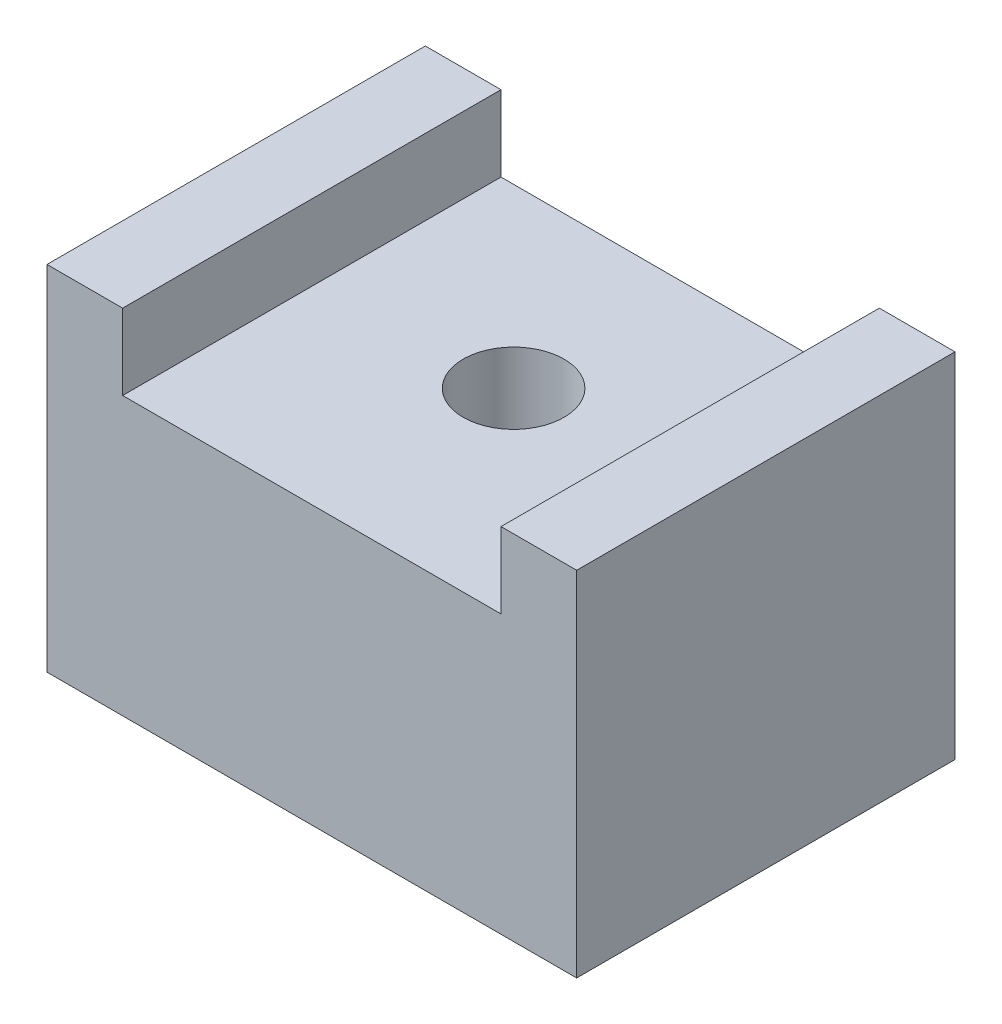
from build123d import *

# Parameters (mm, degrees)
BOSS_EXTRUDE1_DEPTH = 15
SKETCH2_R           = 2
CUT_EXTRUDE1_DEPTH  = 11


with BuildPart() as part:
    # Sketch1 → Boss-Extrude1 (new body)
    with BuildSketch(Plane.XY):
        Polygon((7.5, 0), (-7.5, 0), (-7.5, 3), (-10.5, 3), (-10.5, -11), (10.5, -11), (10.5, 3), (7.5, 3), align=None)
    extrude(amount=BOSS_EXTRUDE1_DEPTH)

    # Sketch2 → Cut-Extrude1 (cut)
    with BuildSketch(Plane(origin=(0, 0, 0), x_dir=(1, 0, 0), z_dir=(0, 1, 0))):
        with Locations((0, -7)):
            Circle(SKETCH2_R)
    extrude(amount=-CUT_EXTRUDE1_DEPTH, mode=Mode.SUBTRACT)


solid = part.part
